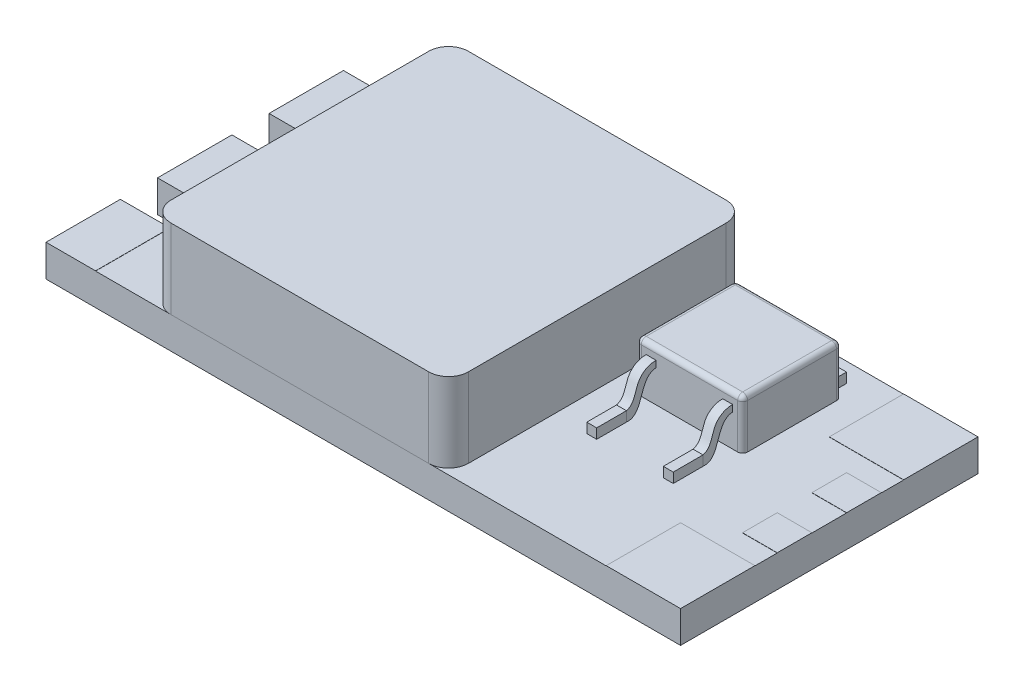
from build123d import *

# Parameters (mm, degrees)
BOSS_EXTRUDE1_DEPTH   = 1.6
SKETCH2_W             = 15
SKETCH2_H             = 15
BOSS_EXTRUDE2_DEPTH   = 4
FILLET1_R             = 1
SKETCH3_W             = 3.75
SKETCH3_H             = 3.75
SKETCH3_W_2           = 1.75
SKETCH3_H_2           = 1.75
SKETCH3_W_3           = 2.5
BOSS_EXTRUDE3_DEPTH   = 0.01
SKETCH4_W             = 5.361600472
SKETCH4_H             = 4.987535322
BOSS_EXTRUDE4_DEPTH   = 2.5
BOSS_EXTRUDE5_DEPTH   = 0.5
SKETCH6_W             = 0.5
SKETCH6_H             = 1.5
BOSS_EXTRUDE5_2_DEPTH = 0.5
SKETCH6_W_2           = 4.361600472
SKETCH6_H_2           = 0.75
BOSS_EXTRUDE5_3_DEPTH = 0.5
BOSS_EXTRUDE6_DEPTH   = 0.5
BOSS_EXTRUDE7_DEPTH   = 0.5
FILLET2_R             = 0.25
FILLET3_R             = 0.25


with BuildPart() as part:
    # Sketch1 → Boss-Extrude1 (new body)
    with BuildSketch(Plane(origin=(0, 0, 0), x_dir=(1, 0, 0), z_dir=(0, 1, 0))):
        Polygon((2.5, 9.375), (2.5, 11.25), (0, 11.25), (0, 15), (32, 15), (32, 0), (0, 0), (0, 3.75), (2.5, 3.75), (2.5, 5.625), (0, 5.625), (0, 9.375), align=None)
    extrude(amount=BOSS_EXTRUDE1_DEPTH)

    # Sketch3 → Boss-Extrude3 (add)
    with BuildSketch(Plane(origin=(0, 1.6, 0), x_dir=(1, 0, 0), z_dir=(0, 1, 0))):
        with Locations((30.125, 13.125)):
            Rectangle(SKETCH3_W, SKETCH3_H)
        with Locations((31.125, 9.25)):
            Rectangle(SKETCH3_W_2, SKETCH3_H_2)
        with Locations((31.125, 5.75)):
            Rectangle(SKETCH3_W_2, SKETCH3_H_2)
        with Locations((30.125, 1.875)):
            Rectangle(SKETCH3_W, SKETCH3_H)
        with Locations((1.25, 13.125)):
            Rectangle(SKETCH3_W_3, SKETCH3_H)
        with Locations((1.25, 7.5)):
            Rectangle(SKETCH3_W_3, SKETCH3_H)
        with Locations((1.25, 1.875)):
            Rectangle(SKETCH3_W_3, SKETCH3_H)
    extrude(amount=BOSS_EXTRUDE3_DEPTH)

    # Sketch4 → Boss-Extrude4 (add)
    with BuildSketch(Plane(origin=(0, 1.6, 0), x_dir=(1, 0, 0), z_dir=(0, 1, 0))):
        with Locations((24.163228826, 10.781587961)):
            Rectangle(SKETCH4_W, SKETCH4_H)
    extrude(amount=BOSS_EXTRUDE4_DEPTH)

    # Fillet2
    fillet2_edges = [part.edges().sort_by_distance(p)[0] for p in [
        (21.48242859, 2.85, -8.2878203),
        (26.844029062, 2.85, -8.2878203),
        (26.844029062, 2.85, -13.275355622),
        (21.48242859, 2.85, -13.275355622),
    ]]
    fillet(fillet2_edges, radius=FILLET2_R)

    # Fillet3
    fillet3_edges = [part.edges().sort_by_distance(p)[0] for p in [
        (21.48242859, 4.1, -10.781587961),
        (24.163228826, 4.1, -13.275355622),
        (24.163228826, 4.1, -8.2878203),
        (26.844029062, 4.1, -10.781587961),
        (26.770805757, 4.1, -13.202132318),
        (26.770805757, 4.1, -8.361043604),
        (21.555651895, 4.1, -8.361043604),
        (21.555651895, 4.1, -13.202132318),
    ]]
    fillet(fillet3_edges, radius=FILLET3_R)


with BuildPart() as body_2:
    # Sketch2 → Boss-Extrude2 (new body)
    with BuildSketch(Plane(origin=(0, 1.6, 0), x_dir=(1, 0, 0), z_dir=(0, 1, 0))):
        with Locations((12.8, 7.5)):
            Rectangle(SKETCH2_W, SKETCH2_H)
    extrude(amount=BOSS_EXTRUDE2_DEPTH)

    # Fillet1
    fillet1_edges = [body_2.edges().sort_by_distance(p)[0] for p in [
        (5.3, 3.6, -15),
        (20.3, 3.6, -15),
        (20.3, 3.6, 0),
        (5.3, 3.6, 0),
    ]]
    fillet(fillet1_edges, radius=FILLET1_R)


with BuildPart() as body_3:
    # Sketch6 → Boss-Extrude5 (new body)
    with BuildSketch(Plane(origin=(0, 1.6, 0), x_dir=(1, 0, 0), z_dir=(0, 1, 0))):
        Polygon((26.344029062, 6.628226466), (26.344029062, 6.7878203), (25.844029062, 6.7878203), (25.844029062, 6.628226466), (25.844029062, 5.2878203), (26.344029062, 5.2878203), align=None)
    extrude(amount=BOSS_EXTRUDE5_DEPTH)


with BuildPart() as body_4:
    # Sketch6 → Boss-Extrude5 2 (new body)
    with BuildSketch(Plane(origin=(0, 1.6, 0), x_dir=(1, 0, 0), z_dir=(0, 1, 0))):
        with Locations((22.23242859, 6.0378203)):
            Rectangle(SKETCH6_W, SKETCH6_H)
    extrude(amount=BOSS_EXTRUDE5_2_DEPTH)


with BuildPart() as body_5:
    # Sketch6 → Boss-Extrude5 3 (new body)
    with BuildSketch(Plane(origin=(0, 1.6, 0), x_dir=(1, 0, 0), z_dir=(0, 1, 0))):
        with Locations((24.163228826, 13.650355622)):
            Rectangle(SKETCH6_W_2, SKETCH6_H_2)
    extrude(amount=BOSS_EXTRUDE5_3_DEPTH)


with BuildPart() as body_6:
    # Sketch7 → Boss-Extrude6 (new body)
    with BuildSketch(Plane(origin=(26.344029062, 0, 0), x_dir=(0, 0, -1), z_dir=(1, 0, 0))):
        with BuildLine():
            add(Edge.make_bspline(
                [(6.7878203, 2.1), (7.230171652, 2.215377346), (7.192285938, 3.194271107), (7.947516495, 3.566089293), (8.2878203, 3.549808919)],
                knots=[0, 0, 0, 0, 0.555688798, 1, 1, 1, 1], degree=3))
            Line((8.2878203, 3.549808919), (8.2878203, 3.226600806))
            add(Edge.make_bspline(
                [(6.7878203, 1.6), (7.7187684, 1.510074693), (7.374744979, 3.184552482), (8.2878203, 3.226600806)],
                knots=[0, 0, 0, 0, 1, 1, 1, 1], degree=3))
            Line((6.7878203, 1.6), (6.7878203, 2.1))
        make_face()
    extrude(amount=-BOSS_EXTRUDE6_DEPTH)


with BuildPart() as body_7:
    # Sketch8 → Boss-Extrude7 (new body)
    with BuildSketch(Plane(origin=(22.48242859, 0, 0), x_dir=(0, 0, -1), z_dir=(1, 0, 0))):
        with BuildLine():
            Line((6.7878203, 2.1), (6.7878203, 1.6))
            add(Edge.make_bspline(
                [(6.7878203, 1.6), (7.7187684, 1.510074693), (7.374744979, 3.184552482), (8.2878203, 3.226600806)],
                knots=[0, 0, 0, 0, 1, 1, 1, 1], degree=3))
            Line((8.2878203, 3.226600806), (8.2878203, 3.549808919))
            add(Edge.make_bspline(
                [(8.2878203, 3.549808919), (7.947516495, 3.566089293), (7.192285938, 3.194271107), (7.230171652, 2.215377346), (6.7878203, 2.1)],
                knots=[0, 0, 0, 0, 0.444311202, 1, 1, 1, 1], degree=3))
        make_face()
    extrude(amount=-BOSS_EXTRUDE7_DEPTH)


solid = Compound([part.part, body_2.part, body_3.part, body_4.part, body_5.part, body_6.part, body_7.part])
